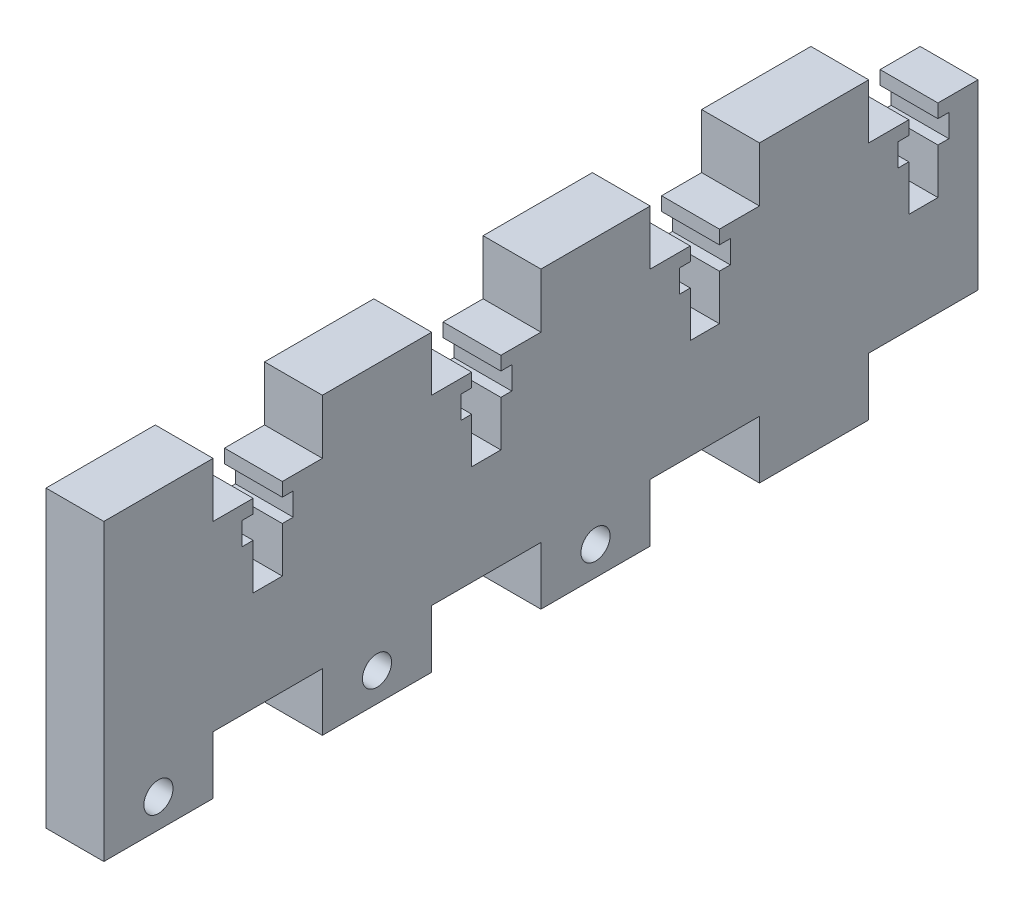
from build123d import *

# Parameters (mm, degrees)
SKETCH1_W           = 96
SKETCH1_H           = 20
BOSS_EXTRUDE1_DEPTH = 6.35
SKETCH2_W           = 12
SKETCH2_H           = 6
SKETCH2_H_2         = 6.35
BOSS_EXTRUDE2_DEPTH = 6.35
SKETCH3_R           = 1.6
CUT_EXTRUDE1_DEPTH  = 10


with BuildPart() as part:
    # Sketch1 → Boss-Extrude1 (new body)
    with BuildSketch(Plane(origin=(0, 0, 0), x_dir=(0, 0, -1), z_dir=(1, 0, 0))):
        Rectangle(SKETCH1_W, SKETCH1_H)
    extrude(amount=BOSS_EXTRUDE1_DEPTH)

    # Sketch2 → Boss-Extrude2 (add)
    with BuildSketch(Plane(origin=(6.35, 0, 0), x_dir=(0, 0, -1), z_dir=(1, 0, 0))):
        with Locations((-18, 13)):
            Rectangle(SKETCH2_W, SKETCH2_H)
        with Locations((-42, 13)):
            Rectangle(SKETCH2_W, SKETCH2_H)
        with Locations((6, 13)):
            Rectangle(SKETCH2_W, SKETCH2_H)
        with Locations((30, 13)):
            Rectangle(SKETCH2_W, SKETCH2_H)
        with Locations((6, -13.175)):
            Rectangle(SKETCH2_W, SKETCH2_H_2)
        with Locations((30, -13.175)):
            Rectangle(SKETCH2_W, SKETCH2_H_2)
        with Locations((-18, -13.175)):
            Rectangle(SKETCH2_W, SKETCH2_H_2)
        with Locations((-42, -13.175)):
            Rectangle(SKETCH2_W, SKETCH2_H_2)
    extrude(amount=-BOSS_EXTRUDE2_DEPTH)

    # Sketch3 → Cut-Extrude1 (cut)
    with BuildSketch(Plane(origin=(6.35, 0, 0), x_dir=(0, 0, -1), z_dir=(1, 0, 0))):
        with Locations((-42, -13.175)):
            Circle(SKETCH3_R)
        with Locations((-18, -13.175)):
            Circle(SKETCH3_R)
        with Locations((6, -13.175)):
            Circle(SKETCH3_R)
        Polygon((-31.6, 10), (-31.6, 8.5), (-32.8, 8.5), (-32.8, 6), (-31.6, 6), (-31.6, 1), (-28.4, 1), (-28.4, 6), (-27.2, 6), (-27.2, 8.5), (-28.4, 8.5), (-28.4, 10), align=None)
        Polygon((-7.6, 10), (-7.6, 8.5), (-8.8, 8.5), (-8.8, 6), (-7.6, 6), (-7.6, 1), (-4.4, 1), (-4.4, 6), (-3.2, 6), (-3.2, 8.5), (-4.4, 8.5), (-4.4, 10), align=None)
        Polygon((16.4, 10), (16.4, 8.5), (15.2, 8.5), (15.2, 6), (16.4, 6), (16.4, 1), (19.6, 1), (19.6, 6), (20.8, 6), (20.8, 8.5), (19.6, 8.5), (19.6, 10), align=None)
        Polygon((40.4, 10), (40.4, 8.5), (39.2, 8.5), (39.2, 6), (40.4, 6), (40.4, 1), (43.6, 1), (43.6, 6), (44.8, 6), (44.8, 8.5), (43.6, 8.5), (43.6, 10), align=None)
    extrude(amount=-CUT_EXTRUDE1_DEPTH, mode=Mode.SUBTRACT)


solid = part.part
